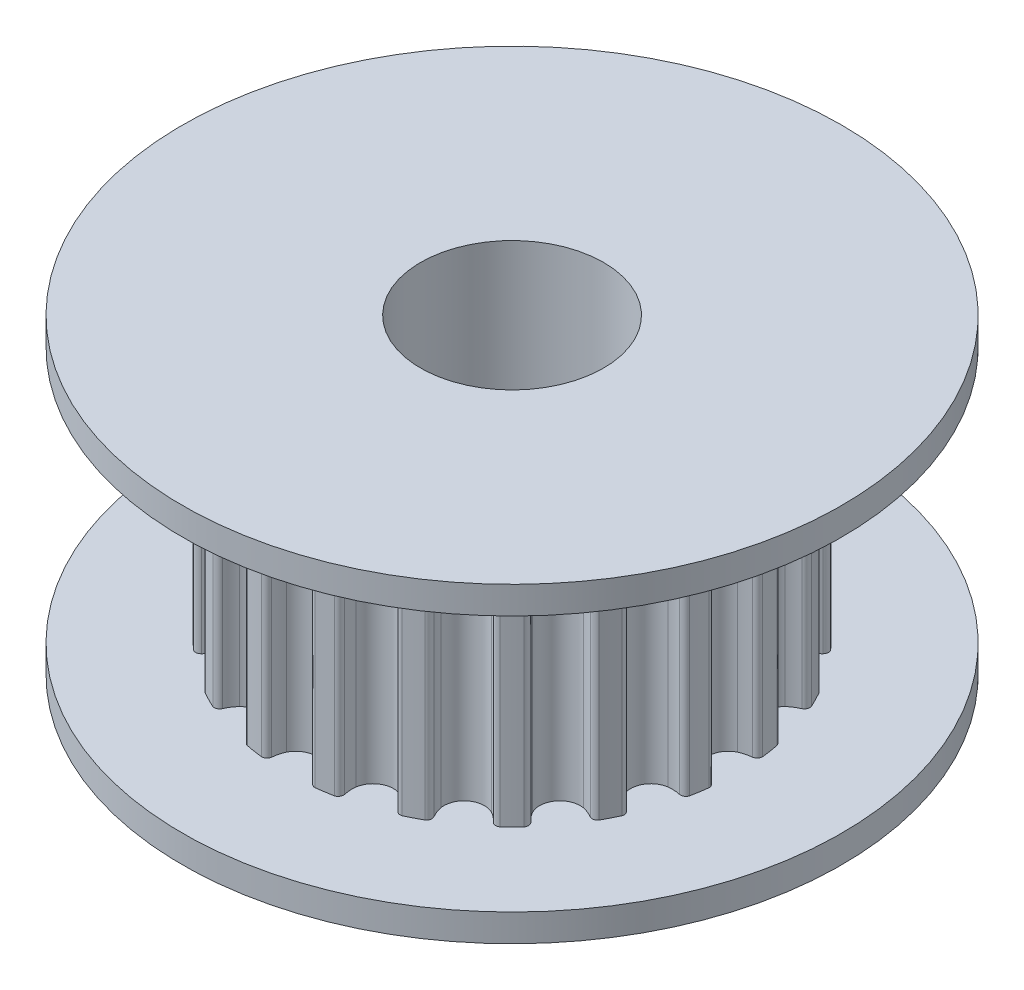
from build123d import *

# Parameters (mm, degrees)
SKETCH2_R           = 6.366203101
SKETCH2_R_2         = 4.366203101
CUT_EXTRUDE1_DEPTH  = 7
BOSS_EXTRUDE1_REACH = 9.75
SKETCH3_R           = 4.366203101


with BuildPart() as part:
    # Sketch1 → Revolve1 (revolve)
    with BuildSketch(Plane.XY):
        Polygon((2.5, 0), (2.5, 8.5), (9, 8.5), (9, 7.75), (6.366203101, 7.75), (6.366203101, 0.75), (9, 0.75), (9, 0), align=None)
    revolve(axis=Axis((0, 0, 0), (0, 1, 0)))

    # Sketch2 → Cut-Extrude1 (cut)
    with BuildSketch(Plane(origin=(0, 0.75, 0), x_dir=(1, 0, 0), z_dir=(0, 1, 0))):
        Circle(SKETCH2_R)
        Circle(SKETCH2_R_2, mode=Mode.SUBTRACT)
    extrude(amount=CUT_EXTRUDE1_DEPTH, mode=Mode.SUBTRACT)

    # Sketch3 → Boss-Extrude1 (add, up to next)
    with BuildSketch(Plane(origin=(0, 0.75, 0), x_dir=(1, 0, 0), z_dir=(0, 1, 0)), mode=Mode.PRIVATE) as boss_extrude1_sk1:
        with BuildLine():
            ThreePointArc((6.039931364, -1.194567246), (6.081158405, -0.96316087), (6.113457662, -0.730340473))
            ThreePointArc((6.113457662, -0.730340473), (6.076174412, -0.631371113), (5.98285854, -0.581600411))
            ThreePointArc((5.98285854, -0.581600411), (5.817334791, -0.552657178), (5.658994178, -0.496407091))
            ThreePointArc((5.658994178, -0.496407091), (5.435086525, -0.291780767), (5.352197724, 0))
            ThreePointArc((5.352197724, 0), (5.435086525, 0.291780767), (5.658994178, 0.496407091))
            ThreePointArc((5.658994178, 0.496407091), (5.817334791, 0.552657178), (5.98285854, 0.581600411))
            ThreePointArc((5.98285854, 0.581600411), (6.076174412, 0.631371113), (6.113457662, 0.730340473))
            ThreePointArc((6.113457662, 0.730340473), (6.081158405, 0.96316087), (6.039931364, 1.194567246))
            ThreePointArc((6.039931364, 1.194567246), (5.973889673, 1.277171543), (5.869761011, 1.295670103))
            ThreePointArc((5.869761011, 1.295670103), (5.703394621, 1.272047103), (5.535421516, 1.276614173))
            ThreePointArc((5.535421516, 1.276614173), (5.259239672, 1.402034102), (5.090242522, 1.653920054))
            ThreePointArc((5.090242522, 1.653920054), (5.078909241, 1.957034102), (5.228625062, 2.220836571))
            ThreePointArc((5.228625062, 2.220836571), (5.361833701, 2.323263522), (5.510312189, 2.401939825))
            ThreePointArc((5.510312189, 2.401939825), (5.583680865, 2.478110765), (5.588556129, 2.583757378))
            ThreePointArc((5.588556129, 2.583757378), (5.48589225, 2.795201715), (5.375174502, 3.0025424))
            ThreePointArc((5.375174502, 3.0025424), (5.286838989, 3.06069575), (5.182090378, 3.0461114))
            ThreePointArc((5.182090378, 3.0461114), (5.031166447, 2.972234549), (4.870003228, 2.924671548))
            ThreePointArc((4.870003228, 2.924671548), (4.568581797, 2.958608105), (4.330018916, 3.145942889))
            ThreePointArc((4.330018916, 3.145942889), (4.225572933, 3.430719304), (4.286441694, 3.727875093))
            ThreePointArc((4.286441694, 3.727875093), (4.38147897, 3.866452647), (4.498378089, 3.987160633))
            ThreePointArc((4.498378089, 3.987160633), (4.544617731, 4.08227567), (4.516607784, 4.184258108))
            ThreePointArc((4.516607784, 4.184258108), (4.35362874, 4.35362874), (4.184258108, 4.516607784))
            ThreePointArc((4.184258108, 4.516607784), (4.08227567, 4.544617731), (3.987160633, 4.498378089))
            ThreePointArc((3.987160633, 4.498378089), (3.866452647, 4.38147897), (3.727875093, 4.286441694))
            ThreePointArc((3.727875093, 4.286441694), (3.430719304, 4.225572933), (3.145942889, 4.330018916))
            ThreePointArc((3.145942889, 4.330018916), (2.958608105, 4.568581797), (2.924671548, 4.870003228))
            ThreePointArc((2.924671548, 4.870003228), (2.972234549, 5.031166447), (3.0461114, 5.182090378))
            ThreePointArc((3.0461114, 5.182090378), (3.06069575, 5.286838989), (3.0025424, 5.375174502))
            ThreePointArc((3.0025424, 5.375174502), (2.795201715, 5.48589225), (2.583757378, 5.588556129))
            ThreePointArc((2.583757378, 5.588556129), (2.478110765, 5.583680865), (2.401939825, 5.510312189))
            ThreePointArc((2.401939825, 5.510312189), (2.323263522, 5.361833701), (2.220836571, 5.228625062))
            ThreePointArc((2.220836571, 5.228625062), (1.957034102, 5.078909241), (1.653920054, 5.090242522))
            ThreePointArc((1.653920054, 5.090242522), (1.402034102, 5.259239672), (1.276614173, 5.535421516))
            ThreePointArc((1.276614173, 5.535421516), (1.272047103, 5.703394621), (1.295670103, 5.869761011))
            ThreePointArc((1.295670103, 5.869761011), (1.277171543, 5.973889673), (1.194567246, 6.039931364))
            ThreePointArc((1.194567246, 6.039931364), (0.96316087, 6.081158405), (0.730340473, 6.113457662))
            ThreePointArc((0.730340473, 6.113457662), (0.631371113, 6.076174412), (0.581600411, 5.98285854))
            ThreePointArc((0.581600411, 5.98285854), (0.552657178, 5.817334791), (0.496407091, 5.658994178))
            ThreePointArc((0.496407091, 5.658994178), (0.291780767, 5.435086525), (0, 5.352197724))
            ThreePointArc((0, 5.352197724), (-0.291780767, 5.435086525), (-0.496407091, 5.658994178))
            ThreePointArc((-0.496407091, 5.658994178), (-0.552657178, 5.817334791), (-0.581600411, 5.98285854))
            ThreePointArc((-0.581600411, 5.98285854), (-0.631371113, 6.076174412), (-0.730340473, 6.113457662))
            ThreePointArc((-0.730340473, 6.113457662), (-0.96316087, 6.081158405), (-1.194567246, 6.039931364))
            ThreePointArc((-1.194567246, 6.039931364), (-1.277171543, 5.973889673), (-1.295670103, 5.869761011))
            ThreePointArc((-1.295670103, 5.869761011), (-1.272047103, 5.703394621), (-1.276614173, 5.535421516))
            ThreePointArc((-1.276614173, 5.535421516), (-1.402034102, 5.259239672), (-1.653920054, 5.090242522))
            ThreePointArc((-1.653920054, 5.090242522), (-1.957034102, 5.078909241), (-2.220836571, 5.228625062))
            ThreePointArc((-2.220836571, 5.228625062), (-2.323263522, 5.361833701), (-2.401939825, 5.510312189))
            ThreePointArc((-2.401939825, 5.510312189), (-2.478110765, 5.583680865), (-2.583757378, 5.588556129))
            ThreePointArc((-2.583757378, 5.588556129), (-2.795201715, 5.48589225), (-3.0025424, 5.375174502))
            ThreePointArc((-3.0025424, 5.375174502), (-3.06069575, 5.286838989), (-3.0461114, 5.182090378))
            ThreePointArc((-3.0461114, 5.182090378), (-2.972234549, 5.031166447), (-2.924671548, 4.870003228))
            ThreePointArc((-2.924671548, 4.870003228), (-2.958608105, 4.568581797), (-3.145942889, 4.330018916))
            ThreePointArc((-3.145942889, 4.330018916), (-3.430719304, 4.225572933), (-3.727875093, 4.286441694))
            ThreePointArc((-3.727875093, 4.286441694), (-3.866452647, 4.38147897), (-3.987160633, 4.498378089))
            ThreePointArc((-3.987160633, 4.498378089), (-4.08227567, 4.544617731), (-4.184258108, 4.516607784))
            ThreePointArc((-4.184258108, 4.516607784), (-4.35362874, 4.35362874), (-4.516607784, 4.184258108))
            ThreePointArc((-4.516607784, 4.184258108), (-4.544617731, 4.08227567), (-4.498378089, 3.987160633))
            ThreePointArc((-4.498378089, 3.987160633), (-4.38147897, 3.866452647), (-4.286441694, 3.727875093))
            ThreePointArc((-4.286441694, 3.727875093), (-4.225572933, 3.430719304), (-4.330018916, 3.145942889))
            ThreePointArc((-4.330018916, 3.145942889), (-4.568581797, 2.958608105), (-4.870003228, 2.924671548))
            ThreePointArc((-4.870003228, 2.924671548), (-5.031166447, 2.972234549), (-5.182090378, 3.0461114))
            ThreePointArc((-5.182090378, 3.0461114), (-5.286838989, 3.06069575), (-5.375174502, 3.0025424))
            ThreePointArc((-5.375174502, 3.0025424), (-5.48589225, 2.795201715), (-5.588556129, 2.583757378))
            ThreePointArc((-5.588556129, 2.583757378), (-5.583680865, 2.478110765), (-5.510312189, 2.401939825))
            ThreePointArc((-5.510312189, 2.401939825), (-5.361833701, 2.323263522), (-5.228625062, 2.220836571))
            ThreePointArc((-5.228625062, 2.220836571), (-5.078909241, 1.957034102), (-5.090242522, 1.653920054))
            ThreePointArc((-5.090242522, 1.653920054), (-5.259239672, 1.402034102), (-5.535421516, 1.276614173))
            ThreePointArc((-5.535421516, 1.276614173), (-5.703394621, 1.272047103), (-5.869761011, 1.295670103))
            ThreePointArc((-5.869761011, 1.295670103), (-5.973889673, 1.277171543), (-6.039931364, 1.194567246))
            ThreePointArc((-6.039931364, 1.194567246), (-6.081158405, 0.96316087), (-6.113457662, 0.730340473))
            ThreePointArc((-6.113457662, 0.730340473), (-6.076174412, 0.631371113), (-5.98285854, 0.581600411))
            ThreePointArc((-5.98285854, 0.581600411), (-5.817334791, 0.552657178), (-5.658994178, 0.496407091))
            ThreePointArc((-5.658994178, 0.496407091), (-5.435086525, 0.291780767), (-5.352197724, 0))
            ThreePointArc((-5.352197724, 0), (-5.435086525, -0.291780767), (-5.658994178, -0.496407091))
            ThreePointArc((-5.658994178, -0.496407091), (-5.817334791, -0.552657178), (-5.98285854, -0.581600411))
            ThreePointArc((-5.98285854, -0.581600411), (-6.076174412, -0.631371113), (-6.113457662, -0.730340473))
            ThreePointArc((-6.113457662, -0.730340473), (-6.081158405, -0.96316087), (-6.039931364, -1.194567246))
            ThreePointArc((-6.039931364, -1.194567246), (-5.973889673, -1.277171543), (-5.869761011, -1.295670103))
            ThreePointArc((-5.869761011, -1.295670103), (-5.703394621, -1.272047103), (-5.535421516, -1.276614173))
            ThreePointArc((-5.535421516, -1.276614173), (-5.259239672, -1.402034102), (-5.090242522, -1.653920054))
            ThreePointArc((-5.090242522, -1.653920054), (-5.078909241, -1.957034102), (-5.228625062, -2.220836571))
            ThreePointArc((-5.228625062, -2.220836571), (-5.361833701, -2.323263522), (-5.510312189, -2.401939825))
            ThreePointArc((-5.510312189, -2.401939825), (-5.583680865, -2.478110765), (-5.588556129, -2.583757378))
            ThreePointArc((-5.588556129, -2.583757378), (-5.48589225, -2.795201715), (-5.375174502, -3.0025424))
            ThreePointArc((-5.375174502, -3.0025424), (-5.286838989, -3.06069575), (-5.182090378, -3.0461114))
            ThreePointArc((-5.182090378, -3.0461114), (-5.031166447, -2.972234549), (-4.870003228, -2.924671548))
            ThreePointArc((-4.870003228, -2.924671548), (-4.568581797, -2.958608105), (-4.330018916, -3.145942889))
            ThreePointArc((-4.330018916, -3.145942889), (-4.225572933, -3.430719304), (-4.286441694, -3.727875093))
            ThreePointArc((-4.286441694, -3.727875093), (-4.38147897, -3.866452647), (-4.498378089, -3.987160633))
            ThreePointArc((-4.498378089, -3.987160633), (-4.544617731, -4.08227567), (-4.516607784, -4.184258108))
            ThreePointArc((-4.516607784, -4.184258108), (-4.35362874, -4.35362874), (-4.184258108, -4.516607784))
            ThreePointArc((-4.184258108, -4.516607784), (-4.08227567, -4.544617731), (-3.987160633, -4.498378089))
            ThreePointArc((-3.987160633, -4.498378089), (-3.866452647, -4.38147897), (-3.727875093, -4.286441694))
            ThreePointArc((-3.727875093, -4.286441694), (-3.430719304, -4.225572933), (-3.145942889, -4.330018916))
            ThreePointArc((-3.145942889, -4.330018916), (-2.958608105, -4.568581797), (-2.924671548, -4.870003228))
            ThreePointArc((-2.924671548, -4.870003228), (-2.972234549, -5.031166447), (-3.0461114, -5.182090378))
            ThreePointArc((-3.0461114, -5.182090378), (-3.06069575, -5.286838989), (-3.0025424, -5.375174502))
            ThreePointArc((-3.0025424, -5.375174502), (-2.795201715, -5.48589225), (-2.583757378, -5.588556129))
            ThreePointArc((-2.583757378, -5.588556129), (-2.478110765, -5.583680865), (-2.401939825, -5.510312189))
            ThreePointArc((-2.401939825, -5.510312189), (-2.323263522, -5.361833701), (-2.220836571, -5.228625062))
            ThreePointArc((-2.220836571, -5.228625062), (-1.957034102, -5.078909241), (-1.653920054, -5.090242522))
            ThreePointArc((-1.653920054, -5.090242522), (-1.402034102, -5.259239672), (-1.276614173, -5.535421516))
            ThreePointArc((-1.276614173, -5.535421516), (-1.272047103, -5.703394621), (-1.295670103, -5.869761011))
            ThreePointArc((-1.295670103, -5.869761011), (-1.277171543, -5.973889673), (-1.194567246, -6.039931364))
            ThreePointArc((-1.194567246, -6.039931364), (-0.96316087, -6.081158405), (-0.730340473, -6.113457662))
            ThreePointArc((-0.730340473, -6.113457662), (-0.631371113, -6.076174412), (-0.581600411, -5.98285854))
            ThreePointArc((-0.581600411, -5.98285854), (-0.552657178, -5.817334791), (-0.496407091, -5.658994178))
            ThreePointArc((-0.496407091, -5.658994178), (-0.291780767, -5.435086525), (0, -5.352197724))
            ThreePointArc((0, -5.352197724), (0.291780767, -5.435086525), (0.496407091, -5.658994178))
            ThreePointArc((0.496407091, -5.658994178), (0.552657178, -5.817334791), (0.581600411, -5.98285854))
            ThreePointArc((0.581600411, -5.98285854), (0.631371113, -6.076174412), (0.730340473, -6.113457662))
            ThreePointArc((0.730340473, -6.113457662), (0.96316087, -6.081158405), (1.194567246, -6.039931364))
            ThreePointArc((1.194567246, -6.039931364), (1.277171543, -5.973889673), (1.295670103, -5.869761011))
            ThreePointArc((1.295670103, -5.869761011), (1.272047103, -5.703394621), (1.276614173, -5.535421516))
            ThreePointArc((1.276614173, -5.535421516), (1.402034102, -5.259239672), (1.653920054, -5.090242522))
            ThreePointArc((1.653920054, -5.090242522), (1.957034102, -5.078909241), (2.220836571, -5.228625062))
            ThreePointArc((2.220836571, -5.228625062), (2.323263522, -5.361833701), (2.401939825, -5.510312189))
            ThreePointArc((2.401939825, -5.510312189), (2.478110765, -5.583680865), (2.583757378, -5.588556129))
            ThreePointArc((2.583757378, -5.588556129), (2.795201715, -5.48589225), (3.0025424, -5.375174502))
            ThreePointArc((3.0025424, -5.375174502), (3.06069575, -5.286838989), (3.0461114, -5.182090378))
            ThreePointArc((3.0461114, -5.182090378), (2.972234549, -5.031166447), (2.924671548, -4.870003228))
            ThreePointArc((2.924671548, -4.870003228), (2.958608105, -4.568581797), (3.145942889, -4.330018916))
            ThreePointArc((3.145942889, -4.330018916), (3.430719304, -4.225572933), (3.727875093, -4.286441694))
            ThreePointArc((3.727875093, -4.286441694), (3.866452647, -4.38147897), (3.987160633, -4.498378089))
            ThreePointArc((3.987160633, -4.498378089), (4.08227567, -4.544617731), (4.184258108, -4.516607784))
            ThreePointArc((4.184258108, -4.516607784), (4.35362874, -4.35362874), (4.516607784, -4.184258108))
            ThreePointArc((4.516607784, -4.184258108), (4.544617731, -4.08227567), (4.498378089, -3.987160633))
            ThreePointArc((4.498378089, -3.987160633), (4.38147897, -3.866452647), (4.286441694, -3.727875093))
            ThreePointArc((4.286441694, -3.727875093), (4.225572933, -3.430719304), (4.330018916, -3.145942889))
            ThreePointArc((4.330018916, -3.145942889), (4.568581797, -2.958608105), (4.870003228, -2.924671548))
            ThreePointArc((4.870003228, -2.924671548), (5.031166447, -2.972234549), (5.182090378, -3.0461114))
            ThreePointArc((5.182090378, -3.0461114), (5.286838989, -3.06069575), (5.375174502, -3.0025424))
            ThreePointArc((5.375174502, -3.0025424), (5.48589225, -2.795201715), (5.588556129, -2.583757378))
            ThreePointArc((5.588556129, -2.583757378), (5.583680865, -2.478110765), (5.510312189, -2.401939825))
            ThreePointArc((5.510312189, -2.401939825), (5.361833701, -2.323263522), (5.228625062, -2.220836571))
            ThreePointArc((5.228625062, -2.220836571), (5.078909241, -1.957034102), (5.090242522, -1.653920054))
            ThreePointArc((5.090242522, -1.653920054), (5.259239672, -1.402034102), (5.535421516, -1.276614173))
            ThreePointArc((5.535421516, -1.276614173), (5.703394621, -1.272047103), (5.869761011, -1.295670103))
            ThreePointArc((5.869761011, -1.295670103), (5.973889673, -1.277171543), (6.039931364, -1.194567246))
        make_face()
        Circle(SKETCH3_R, mode=Mode.SUBTRACT)
    boss_extrude1_tool1 = extrude(boss_extrude1_sk1.sketch, amount=BOSS_EXTRUDE1_REACH, mode=Mode.PRIVATE) - part.part
    add(boss_extrude1_tool1.solids().sort_by_distance((0.936111, 0.75, 5.910373))[0])


solid = part.part
